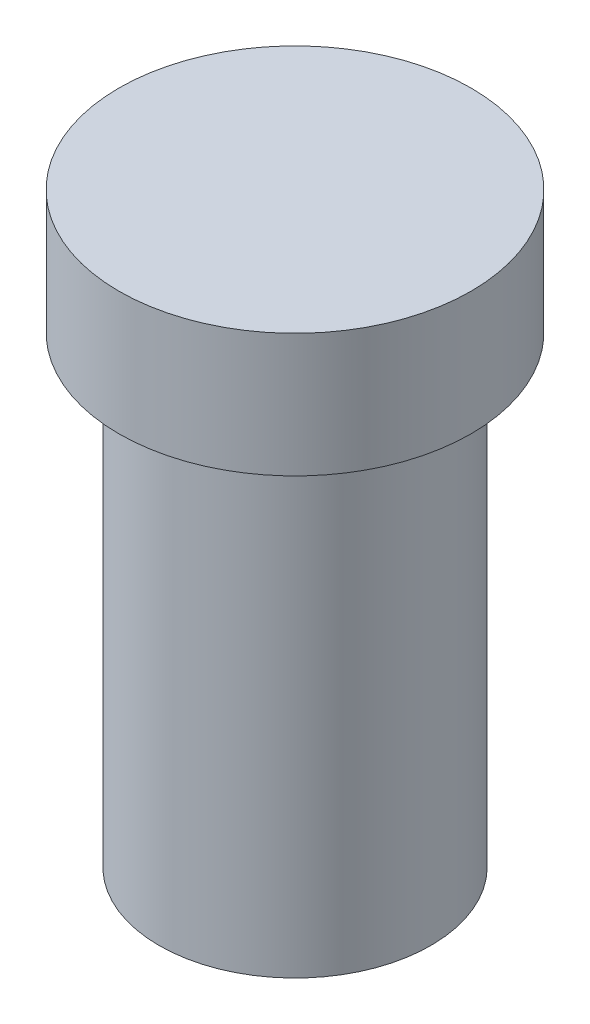
from build123d import *

# Parameters (mm, degrees)
SKETCH1_R           = 22
BOSS_EXTRUDE1_DEPTH = 37.5
SKETCH4_R           = 28.5
BOSS_EXTRUDE2_DEPTH = 20


with BuildPart() as part:
    # Sketch1 → Boss-Extrude1 (new body, symmetric)
    with BuildSketch(Plane(origin=(0, 0, 0), x_dir=(1, 0, 0), z_dir=(0, 1, 0))):
        with Locations(Location((0, 0, 0), (0, 0, 270))):  # turned: the seam where the file's is
            Circle(SKETCH1_R)
    extrude(amount=BOSS_EXTRUDE1_DEPTH, both=True)

    # Sketch4 → Boss-Extrude2 (add)
    with BuildSketch(Plane(origin=(0, 37.5, 0), x_dir=(1, 0, 0), z_dir=(0, 1, 0))):
        with Locations(Location((0, 0, 0), (0, 0, 270))):  # turned: the seam where the file's is
            Circle(SKETCH4_R)
    extrude(amount=BOSS_EXTRUDE2_DEPTH)


solid = part.part
